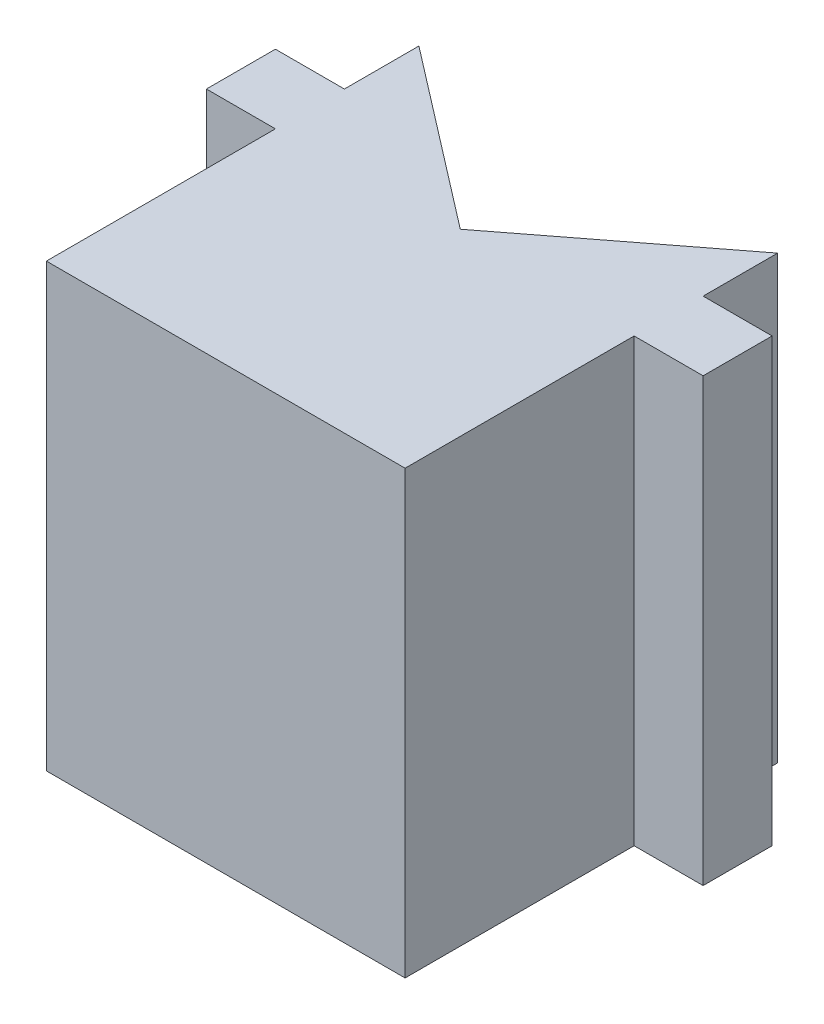
from build123d import *

# Parameters (mm, degrees)
SKETCH2_W           = 6.35
SKETCH2_H           = 6.35
BOSS_EXTRUDE1_DEPTH = 40.64
BOSS_EXTRUDE2_DEPTH = 2.54


with BuildPart() as part:
    # Sketch2 → Boss-Extrude1 (new body)
    with BuildSketch(Plane(origin=(0, 0, 0), x_dir=(1, 0, 0), z_dir=(0, 1, 0))):
        Polygon((-33.02, 0), (0, 0), (0, 21.082), (0, 27.432), (0, 34.29), (-16.51, 21.59), (-33.02, 34.29), (-33.02, 27.432), (-33.02, 21.082), align=None)
        with Locations((-36.195, 24.257)):
            Rectangle(SKETCH2_W, SKETCH2_H)
        with Locations((3.175, 24.257)):
            Rectangle(SKETCH2_W, SKETCH2_H)
    extrude(amount=BOSS_EXTRUDE1_DEPTH)

    # Sketch5 → Boss-Extrude2 (add)
    with BuildSketch(Plane.XZ):
        Polygon((0, -34.29), (-33.02, -34.29), (-16.51, -21.59), align=None)
    extrude(amount=-BOSS_EXTRUDE2_DEPTH)


solid = part.part
